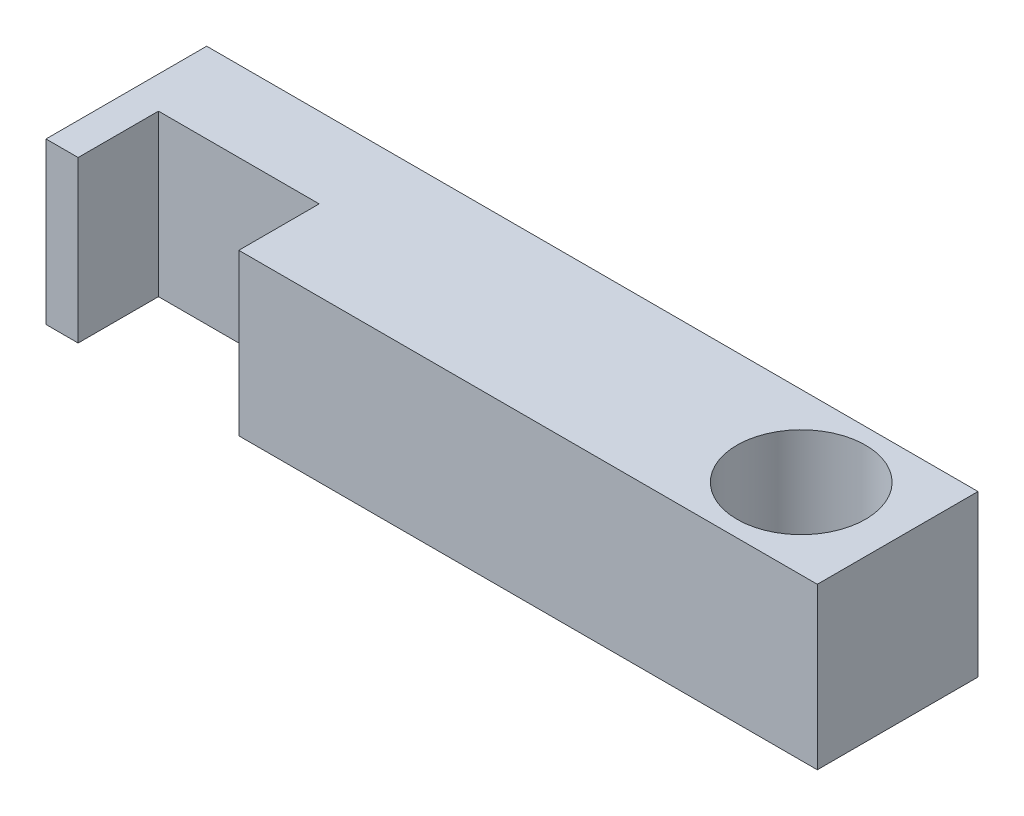
from build123d import *

# Parameters (mm, degrees)
SKETCH_1_R      = 4
EXTRUDE_1_DEPTH = 5


with BuildPart() as part:
    # 草圖1 → 填料-伸長1 (new body, symmetric)
    with BuildSketch(Plane(origin=(0, 0, 0), x_dir=(1, 0, 0), z_dir=(0, 1, 0))):
        Polygon((-40, -5), (-40, 0), (-30, 0), (-30, -5), (6, -5), (6, 5), (-42, 5), (-42, -5), align=None)
        Circle(SKETCH_1_R, mode=Mode.SUBTRACT)
    extrude(amount=EXTRUDE_1_DEPTH, both=True)


solid = part.part
